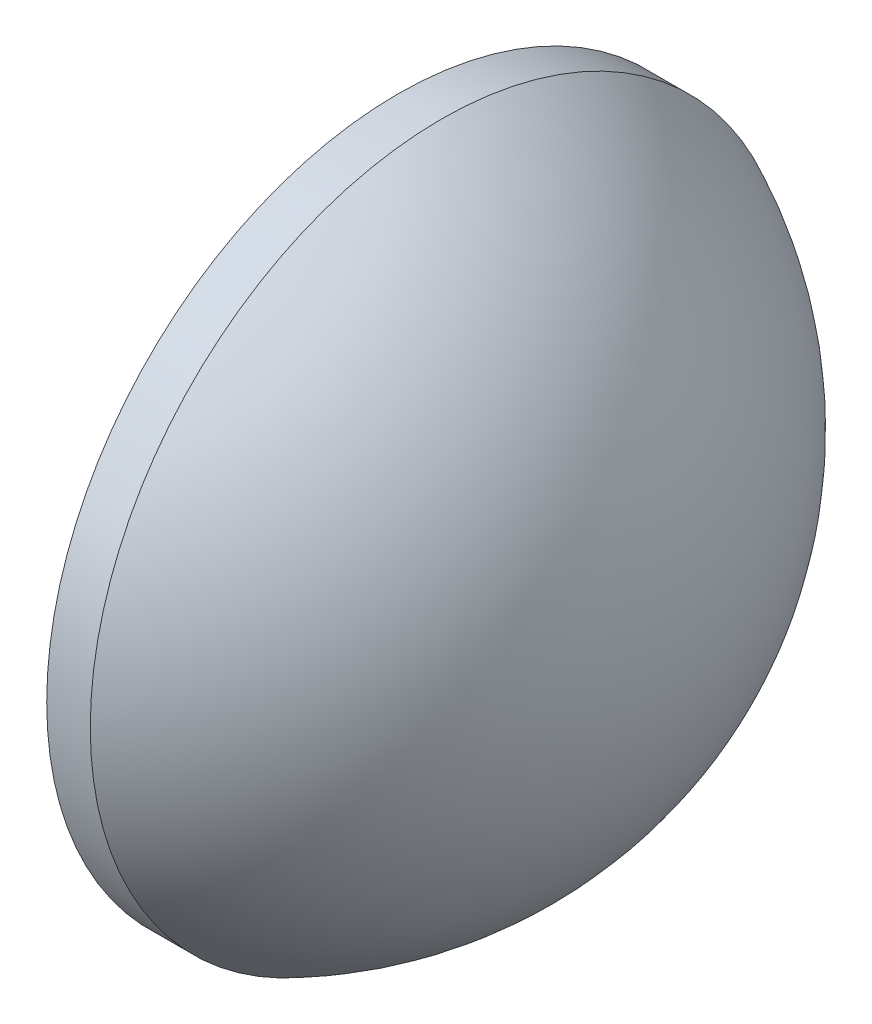
from build123d import *


with BuildPart() as part:
    # 草图1 → 旋转1 (revolve)
    with BuildSketch(Plane.XY, mode=Mode.PRIVATE) as revolve_1_sk:
        with BuildLine():
            Line((488.366874008, 171.715697297), (488.366874008, 184.215697297))
            Line((488.366874008, 184.215697297), (489.916874008, 184.215697297))
            ThreePointArc((489.916874008, 184.215697297), (495.711000781, 179.122661925), (497.866874008, 171.715697297))
            Line((497.866874008, 171.715697297), (488.366874008, 171.715697297))
        make_face()
    revolve(revolve_1_sk.sketch.rotate(Axis((486.854842766, 171.715697297, 0), (1, 0, 0)), 180), axis=Axis((486.854842766, 171.715697297, 0), (1, 0, 0)))  # turned: the seam where the file's is


solid = part.part
